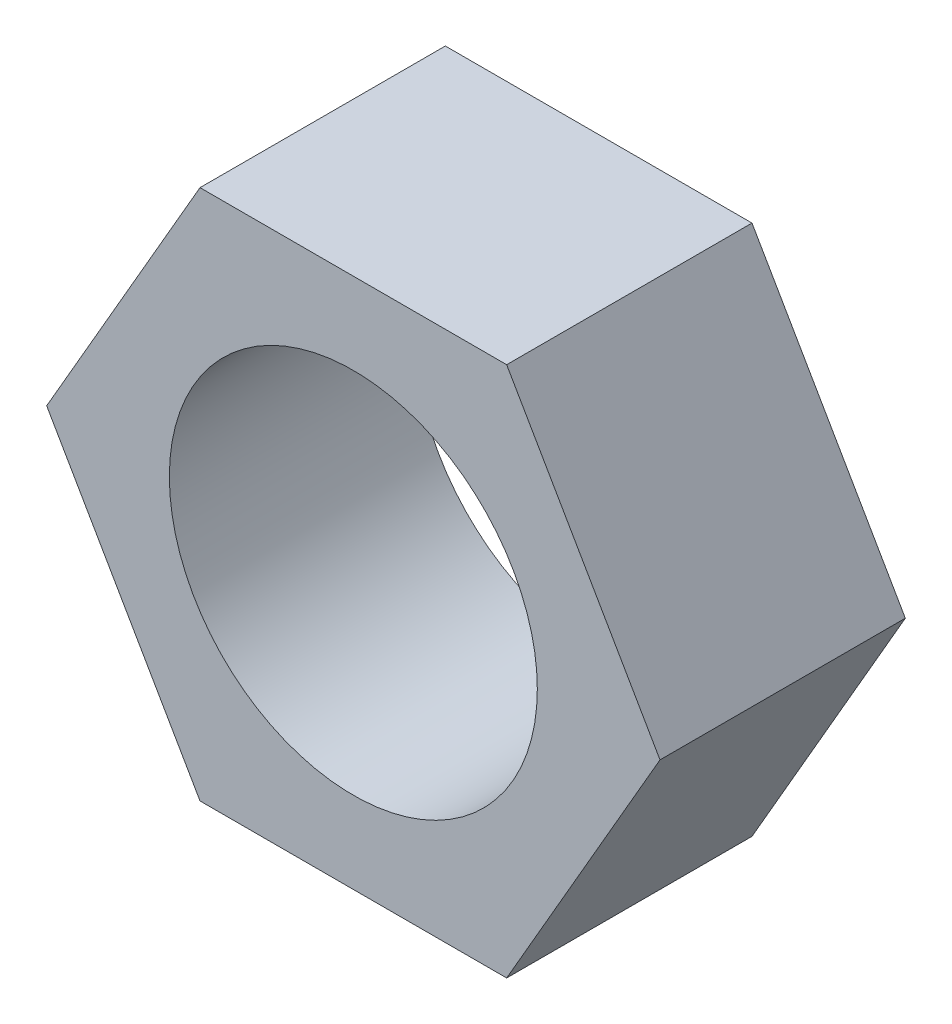
from build123d import *

# Parameters (mm, degrees)
SALIENTE_EXTRUIR1_DEPTH = 4
CROQUIS3_R              = 3
CORTAR_EXTRUIR1_DEPTH   = 5


with BuildPart() as part:
    # Croquis2 → Saliente-Extruir1 (new body)
    with BuildSketch(Plane.XY):
        Polygon((5, 0), (2.5, 4.330127019), (-2.5, 4.330127019), (-5, 0), (-2.5, -4.330127019), (2.5, -4.330127019), align=None)
    extrude(amount=SALIENTE_EXTRUIR1_DEPTH)

    # Croquis3 → Cortar-Extruir1 (cut, through all)
    with BuildSketch(Plane(origin=(0, 0, 0), x_dir=(-1, 0, 0), z_dir=(0, 0, -1))):
        Circle(CROQUIS3_R)
    extrude(amount=-CORTAR_EXTRUIR1_DEPTH, mode=Mode.SUBTRACT)


solid = part.part
